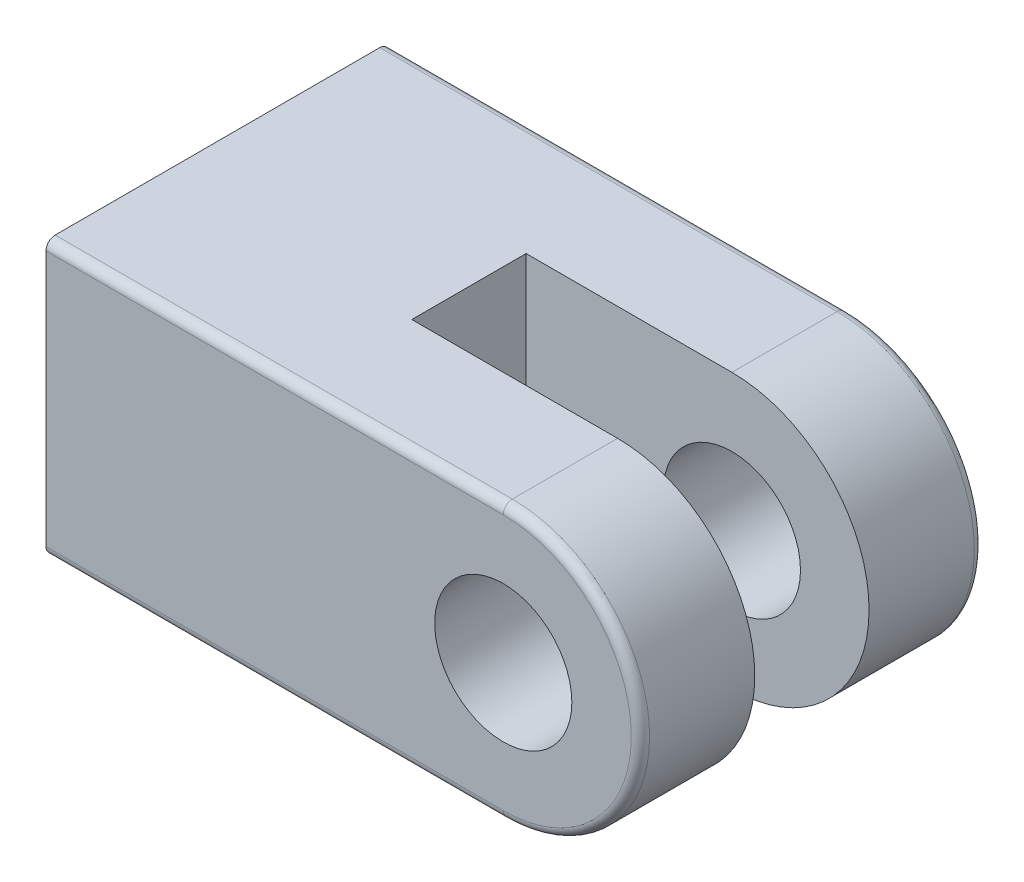
from build123d import *

# Parameters (mm, degrees)
BOSS_EXTRUDE1_DEPTH     = 19.05
SKETCH2_W               = 19.05
SKETCH2_H               = 6.35
CUT_EXTRUDE1_DEPTH      = 8.62
CUT_EXTRUDE1_DEPTH_BACK = 8.62
SKETCH3_R               = 3.81
CUT_EXTRUDE2_DEPTH      = 20.05
FILLET1_R               = 0.508


with BuildPart() as part:
    # Sketch1 → Boss-Extrude1 (new body)
    with BuildSketch(Plane.XY):
        with BuildLine():
            Line((0, 7.62), (-25.4, 7.62))
            Line((-25.4, 7.62), (-25.4, -7.62))
            Line((-25.4, -7.62), (0, -7.62))
            ThreePointArc((0, -7.62), (7.62, 0), (0, 7.62))
        make_face()
    extrude(amount=BOSS_EXTRUDE1_DEPTH)

    # Sketch2 → Cut-Extrude1 (cut, two sides)
    with BuildSketch(Plane(origin=(0, 0, 0), x_dir=(1, 0, 0), z_dir=(0, 1, 0))) as cut_extrude1_sk:
        with Locations((-1.905, -9.525)):
            Rectangle(SKETCH2_W, SKETCH2_H)
    extrude(amount=CUT_EXTRUDE1_DEPTH, mode=Mode.SUBTRACT)
    extrude(cut_extrude1_sk.sketch, amount=-CUT_EXTRUDE1_DEPTH_BACK, mode=Mode.SUBTRACT)

    # Sketch3 → Cut-Extrude2 (cut, through all)
    with BuildSketch(Plane.XY.offset(19.05)):
        Circle(SKETCH3_R)
    extrude(amount=-CUT_EXTRUDE2_DEPTH, mode=Mode.SUBTRACT)

    # Fillet1
    fillet1_edges = [part.edges().sort_by_distance(p)[0] for p in [
        (-12.7, -7.62, 19.05),
        (7.62, 0, 19.05),
        (-12.7, -7.62, 0),
        (-12.7, 7.62, 0),
        (7.62, 0, 0),
        (-12.7, 7.62, 19.05),
    ]]
    fillet(fillet1_edges, radius=FILLET1_R)


solid = part.part
